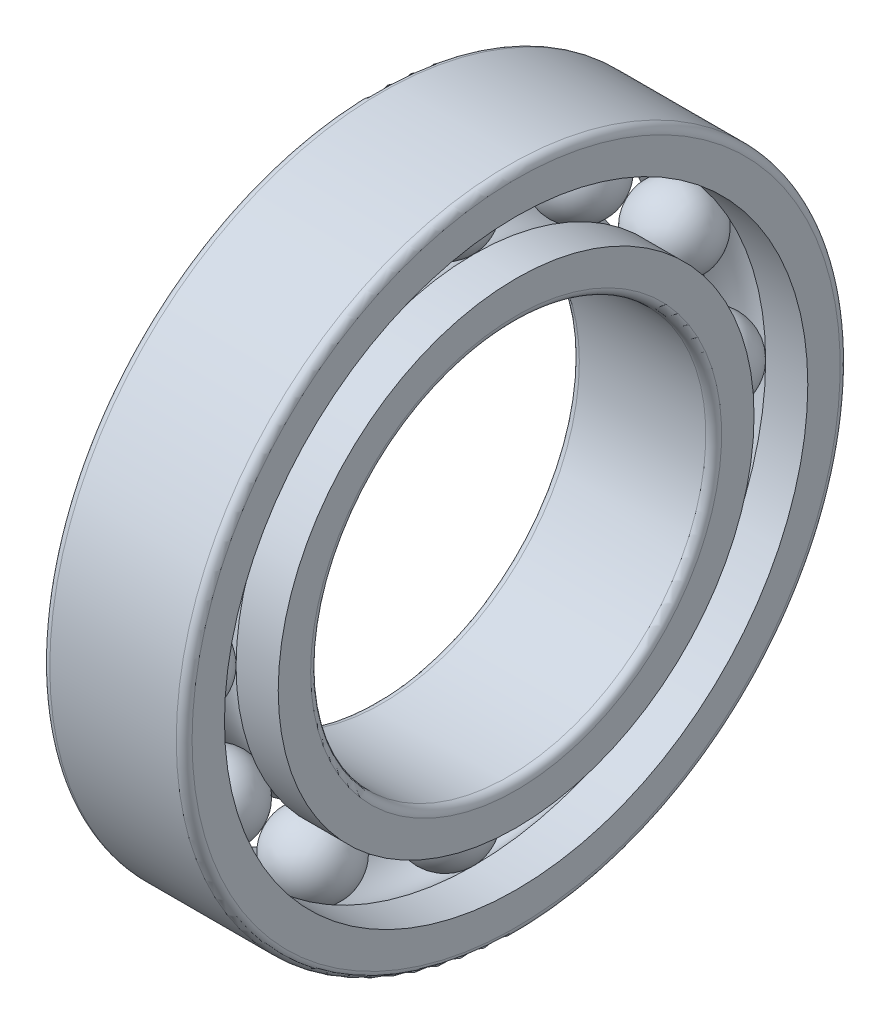
from build123d import *

# Parameters (mm, degrees)
FILLET_1_R               = 0.5
FILLET_2_R               = 0.5
PATTERN_CIRCULAR_1_COUNT = 12


with BuildPart() as part:
    # Эскиз1 → Повернуть1 (revolve)
    with BuildSketch(Plane.XY):
        with BuildLine():
            Line((0, 15.05), (0, 12.5))
            Line((0, 12.5), (9, 12.5))
            Line((9, 12.5), (9, 15.05))
            Line((9, 15.05), (6.333030278, 15.05))
            ThreePointArc((6.333030278, 15.05), (4.5, 14.25), (2.666969722, 15.05))
            Line((2.666969722, 15.05), (0, 15.05))
        make_face()
        with BuildLine():
            Line((9, 18.45), (9, 21))
            Line((9, 21), (0, 21))
            Line((0, 21), (0, 18.45))
            Line((0, 18.45), (2.666969722, 18.45))
            ThreePointArc((2.666969722, 18.45), (4.5, 19.25), (6.333030278, 18.45))
            Line((6.333030278, 18.45), (9, 18.45))
        make_face()
    revolve(axis=Axis((0, 0, 0), (1, 0, 0)))

    # Скругление1
    fillet_1_edges = [part.edges().sort_by_distance(p)[0] for p in [
        (9, -21, 0),
        (0, -21, 0),
    ]]
    fillet(fillet_1_edges, radius=FILLET_1_R)

    # Скругление2
    fillet_2_edges = [part.edges().sort_by_distance(p)[0] for p in [
        (9, -12.5, 0),
        (0, -12.5, 0),
    ]]
    fillet(fillet_2_edges, radius=FILLET_2_R)


with BuildPart() as body_2:
    # Эскиз2 → Повернуть4 (revolve)
    with BuildSketch(Plane.XY):
        with BuildLine():
            Line((2, 16.75), (7, 16.75))
            ThreePointArc((7, 16.75), (4.5, 19.25), (2, 16.75))
        make_face()
    revolve(axis=Axis((2, 16.75, 0), (1, 0, 0)))


with BuildPart() as pattern_circular_1_1:
    # Круговой массив1: pattern copy
    add(body_2.part.rotate(Axis((0, 0, 0), (1, 0, 0)), 1 * 360 / PATTERN_CIRCULAR_1_COUNT))


with BuildPart() as pattern_circular_1_2:
    # Круговой массив1: pattern copy
    add(body_2.part.rotate(Axis((0, 0, 0), (1, 0, 0)), 2 * 360 / PATTERN_CIRCULAR_1_COUNT))


with BuildPart() as pattern_circular_1_3:
    # Круговой массив1: pattern copy
    add(body_2.part.rotate(Axis((0, 0, 0), (1, 0, 0)), 3 * 360 / PATTERN_CIRCULAR_1_COUNT))


with BuildPart() as pattern_circular_1_4:
    # Круговой массив1: pattern copy
    add(body_2.part.rotate(Axis((0, 0, 0), (1, 0, 0)), 4 * 360 / PATTERN_CIRCULAR_1_COUNT))


with BuildPart() as pattern_circular_1_5:
    # Круговой массив1: pattern copy
    add(body_2.part.rotate(Axis((0, 0, 0), (1, 0, 0)), 5 * 360 / PATTERN_CIRCULAR_1_COUNT))


with BuildPart() as pattern_circular_1_6:
    # Круговой массив1: pattern copy
    add(body_2.part.rotate(Axis((0, 0, 0), (1, 0, 0)), 6 * 360 / PATTERN_CIRCULAR_1_COUNT))


with BuildPart() as pattern_circular_1_7:
    # Круговой массив1: pattern copy
    add(body_2.part.rotate(Axis((0, 0, 0), (1, 0, 0)), 7 * 360 / PATTERN_CIRCULAR_1_COUNT))


with BuildPart() as pattern_circular_1_8:
    # Круговой массив1: pattern copy
    add(body_2.part.rotate(Axis((0, 0, 0), (1, 0, 0)), 8 * 360 / PATTERN_CIRCULAR_1_COUNT))


with BuildPart() as pattern_circular_1_9:
    # Круговой массив1: pattern copy
    add(body_2.part.rotate(Axis((0, 0, 0), (1, 0, 0)), 9 * 360 / PATTERN_CIRCULAR_1_COUNT))


with BuildPart() as pattern_circular_1_10:
    # Круговой массив1: pattern copy
    add(body_2.part.rotate(Axis((0, 0, 0), (1, 0, 0)), 10 * 360 / PATTERN_CIRCULAR_1_COUNT))


with BuildPart() as pattern_circular_1_11:
    # Круговой массив1: pattern copy
    add(body_2.part.rotate(Axis((0, 0, 0), (1, 0, 0)), 11 * 360 / PATTERN_CIRCULAR_1_COUNT))


solid = Compound([part.part, body_2.part, pattern_circular_1_1.part, pattern_circular_1_2.part, pattern_circular_1_3.part, pattern_circular_1_4.part, pattern_circular_1_5.part, pattern_circular_1_6.part, pattern_circular_1_7.part, pattern_circular_1_8.part, pattern_circular_1_9.part, pattern_circular_1_10.part, pattern_circular_1_11.part])
